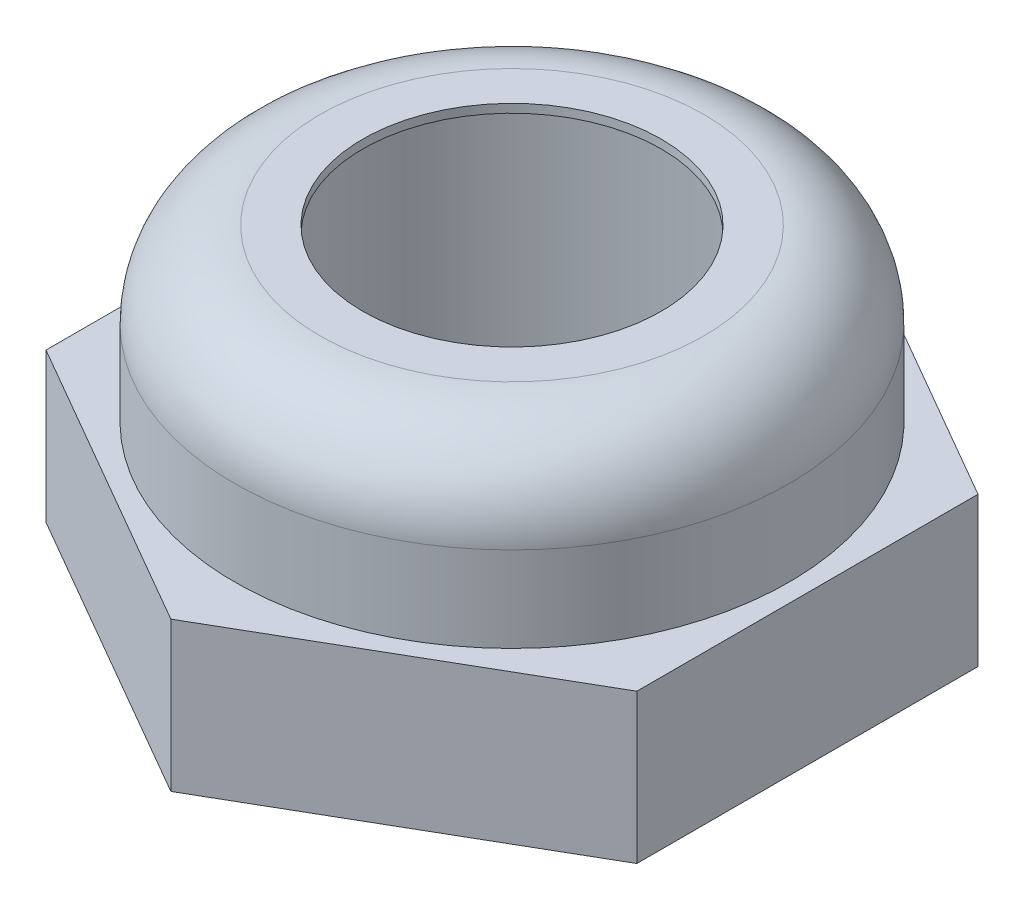
from build123d import *

# Parameters (mm, degrees)
SKETCH_2_R          = 11.601145783
CUT_EXTRUDE_1_DEPTH = 10


with BuildPart() as part:
    # Эскиз1 → Повернуть1 (revolve)
    with BuildSketch(Plane.XY):
        with BuildLine():
            Line((-8, -6.973192061), (-6, -6.973192061))
            Line((-6, -6.973192061), (-6, -0.973192061))
            add(Edge.make_bspline(
                [(-6, -0.973192061), (-5.270413842, 0.380623503), (-3.5, 0.326807939)],
                knots=[0, 0, 0, 1, 1, 1], degree=2))
            Line((-3.5, 0.326807939), (-3.5, 0.526807939))
            Line((-3.5, 0.526807939), (-4.5, 0.526807939))
            ThreePointArc((-4.5, 0.526807939), (-5.914213562, -0.058978499), (-6.5, -1.473192061))
            Line((-6.5, -1.473192061), (-6.5, -3.473192061))
            Line((-6.5, -3.473192061), (-8, -3.473192061))
            Line((-8, -3.473192061), (-8, -6.973192061))
        make_face()
    revolve(axis=Axis((0, -7.792035126, 0), (0, 1, 0)))

    # Эскиз2 → Вырез-Вытянуть1 (cut)
    with BuildSketch(Plane(origin=(0, -3.473192061, 0), x_dir=(1, 0, 0), z_dir=(0, 1, 0))):
        Circle(SKETCH_2_R)
        Polygon((0, 8), (6.92820323, 4), (6.92820323, -4), (0, -8), (-6.92820323, -4), (-6.92820323, 4), align=None, mode=Mode.SUBTRACT)
    extrude(amount=-CUT_EXTRUDE_1_DEPTH, mode=Mode.SUBTRACT)


solid = part.part
